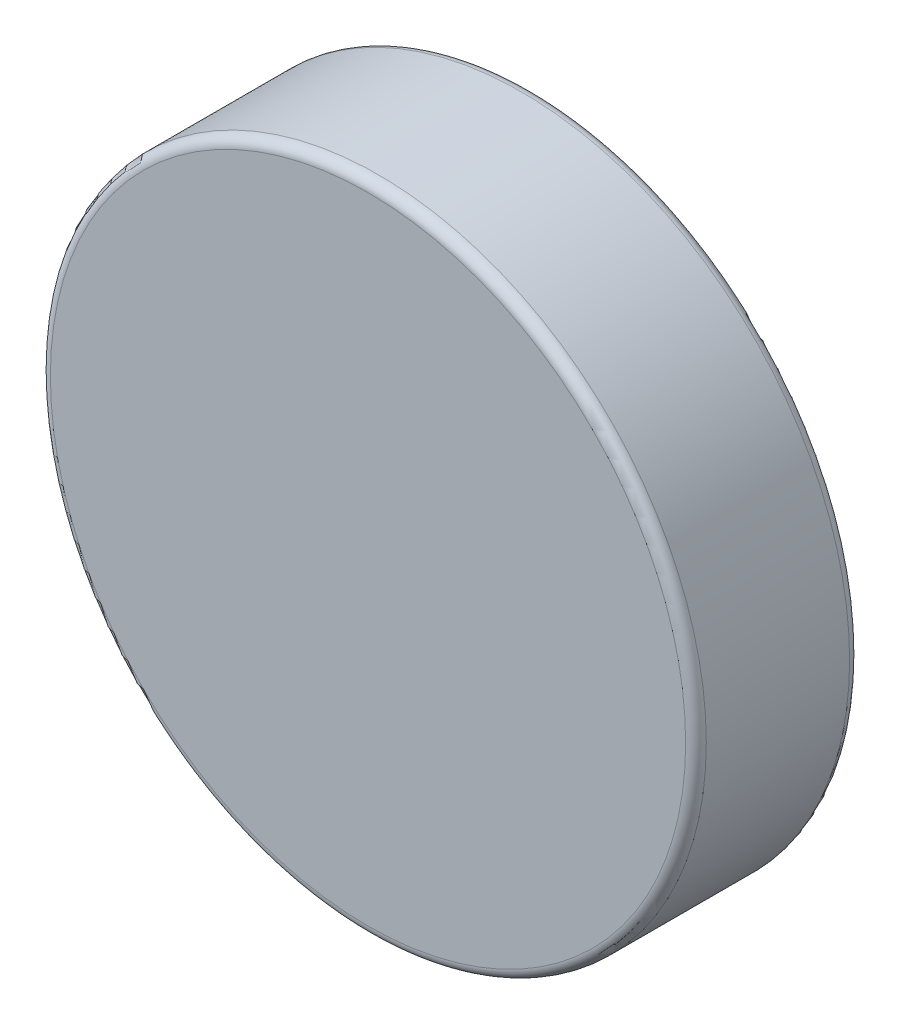
from build123d import *

# Parameters (mm, degrees)
SKETCH2_R           = 3.175
BOSS_EXTRUDE2_DEPTH = 1.5875
FILLET2_R           = 0.1


with BuildPart() as part:
    # Sketch2 → Boss-Extrude2 (new body)
    with BuildSketch(Plane.XY):
        Circle(SKETCH2_R)
    extrude(amount=BOSS_EXTRUDE2_DEPTH)

    # Fillet2
    fillet2_edges = [part.edges().sort_by_distance(p)[0] for p in [
        (-3.175, 0, 0),
        (-3.175, 0, 1.5875),
    ]]
    fillet(fillet2_edges, radius=FILLET2_R)


solid = part.part
